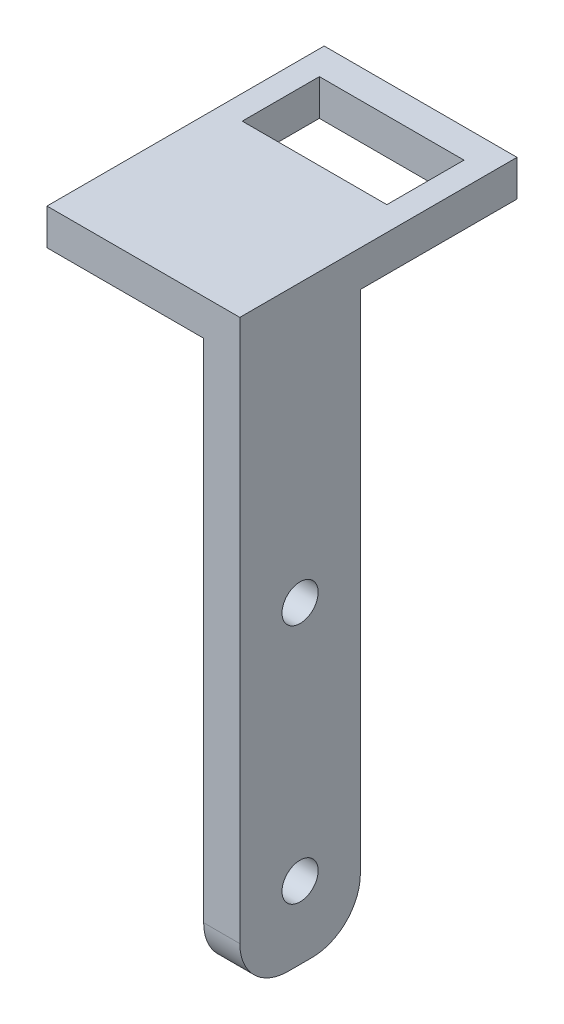
from build123d import *

# Parameters (mm, degrees)
SKETCH1_W                      = 15.875
SKETCH1_H                      = 22.225
SKETCH1_H_2                    = 50.8
BOSS_EXTRUDE1_DEPTH            = 4.7625
F_3_16_0_1875_DIAMETER_HOLE1_D = 4.7625
SKETCH5_W                      = 4.7625
SKETCH5_H                      = 15.875
BOSS_EXTRUDE2_DEPTH            = 4.7625
FILLET1_R                      = 6.35
SKETCH7_W                      = 19.05
SKETCH7_H                      = 10.16
CUT_EXTRUDE1_DEPTH             = 78.7875


with BuildPart() as part:
    # Sketch1 → Boss-Extrude1 (new body)
    with BuildSketch(Plane(origin=(0, 0, 0), x_dir=(0, 0, -1), z_dir=(1, 0, 0))):
        with Locations((0, 36.5125)):
            Rectangle(SKETCH1_W, SKETCH1_H)
        Rectangle(SKETCH1_W, SKETCH1_H_2)
    extrude(amount=BOSS_EXTRUDE1_DEPTH)

    # 3/16 (0.1875) Diameter Hole1 (through all)
    with Locations(Plane(origin=(4.7625, 0, 0), x_dir=(0, 0, -1), z_dir=(1, 0, 0))):
        with Locations((0, -15.875), (0, 15.875)):
            Hole(F_3_16_0_1875_DIAMETER_HOLE1_D / 2)

    # Sketch5 → Boss-Extrude2 (add)
    with BuildSketch(Plane(origin=(0, 47.625, 0), x_dir=(1, 0, 0), z_dir=(0, 1, 0))):
        Polygon((-20.6375, -7.9375), (0, -7.9375), (0, 7.9375), (4.7625, 7.9375), (4.7625, 28.575), (-20.6375, 28.575), align=None)
        with Locations((2.38125, 0)):
            Rectangle(SKETCH5_W, SKETCH5_H)
    extrude(amount=BOSS_EXTRUDE2_DEPTH)

    # Fillet1
    fillet1_edges = [part.edges().sort_by_distance(p)[0] for p in [
        (2.38125, -25.4, 7.9375),
        (2.38125, -25.4, -7.9375),
    ]]
    fillet(fillet1_edges, radius=FILLET1_R)

    # Sketch7 → Cut-Extrude1 (cut, through all)
    with BuildSketch(Plane(origin=(0, 52.3875, 0), x_dir=(1, 0, 0), z_dir=(0, 1, 0))):
        with Locations((-7.9375, 19.685)):
            Rectangle(SKETCH7_W, SKETCH7_H)
    extrude(amount=-CUT_EXTRUDE1_DEPTH, mode=Mode.SUBTRACT)


solid = part.part
